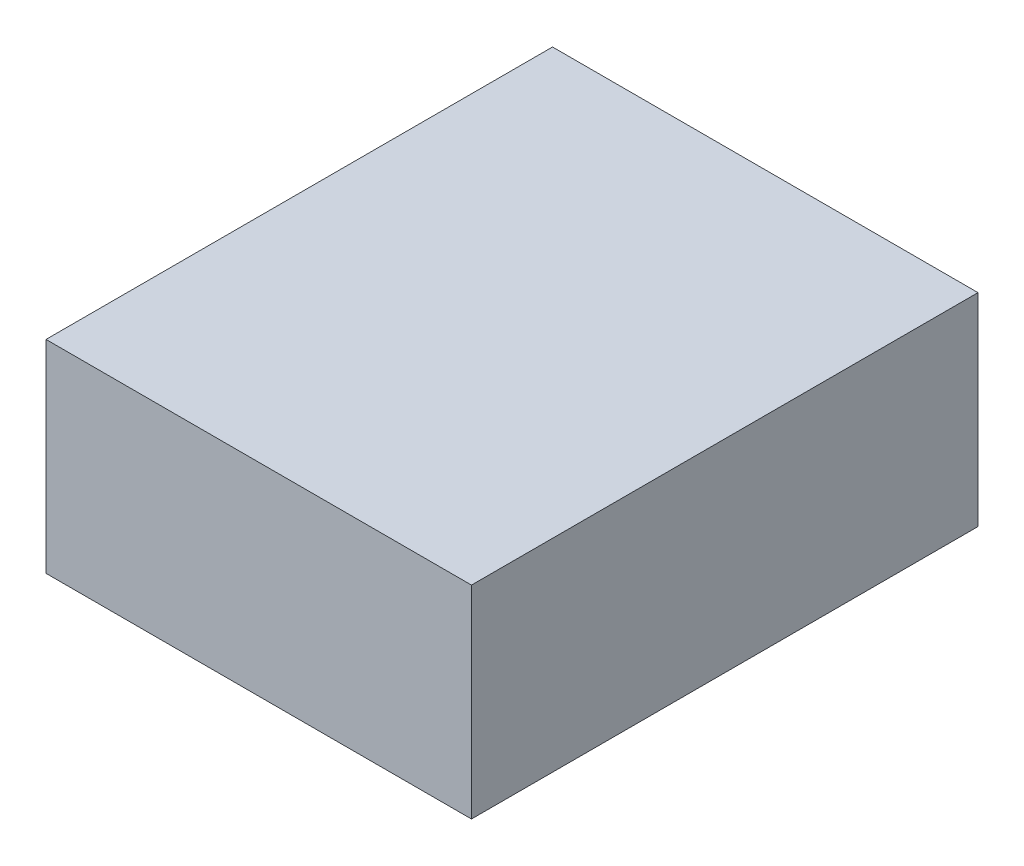
from build123d import *

# Parameters (mm, degrees)
SKETCH1_W           = 1.05
SKETCH1_H           = 1.25
BOSS_EXTRUDE1_DEPTH = 0.5


with BuildPart() as part:
    # Sketch1 → Boss-Extrude1 (new body)
    with BuildSketch(Plane(origin=(0, 0, 0), x_dir=(1, 0, 0), z_dir=(0, 1, 0))):
        with Locations((0.52220925, 0.625)):
            Rectangle(SKETCH1_W, SKETCH1_H)
    extrude(amount=BOSS_EXTRUDE1_DEPTH)


solid = part.part
